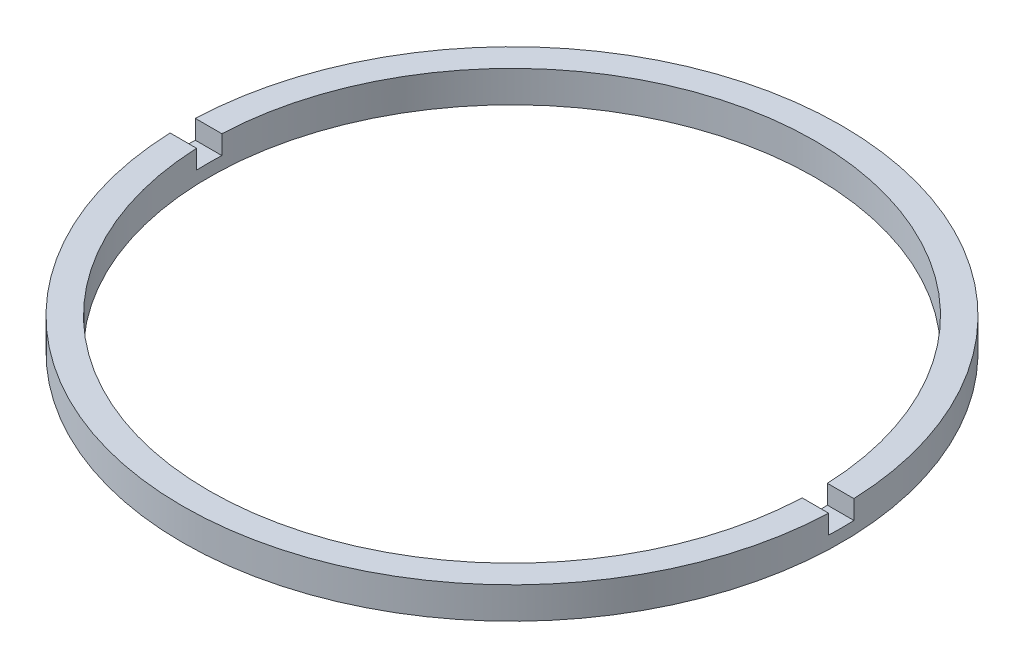
from build123d import *

# Parameters (mm, degrees)
SKETCH_1_W          = 2.1
SKETCH_1_H          = 2.5
SKETCH_2_W          = 53.705080546
SKETCH_2_H          = 2
CUT_EXTRUDE_1_DEPTH = 1.5


with BuildPart() as part:
    # 草图1 → 旋转1 (revolve)
    with BuildSketch(Plane.XY, mode=Mode.PRIVATE) as revolve_1_sk:
        with Locations((25.05, -3.214249787)):
            Rectangle(SKETCH_1_W, SKETCH_1_H)
    revolve(revolve_1_sk.sketch.rotate(Axis((0, 56.260842627, 0), (0, -1, 0)), 90), axis=Axis((0, 56.260842627, 0), (0, -1, 0)))  # turned: the seam where the file's is

    # 草图2 → 切除-拉伸1 (cut)
    with BuildSketch(Plane(origin=(0, -1.964249787, 0), x_dir=(1, 0, 0), z_dir=(0, 1, 0))):
        Rectangle(SKETCH_2_W, SKETCH_2_H)
    extrude(amount=-CUT_EXTRUDE_1_DEPTH, mode=Mode.SUBTRACT)


solid = part.part
